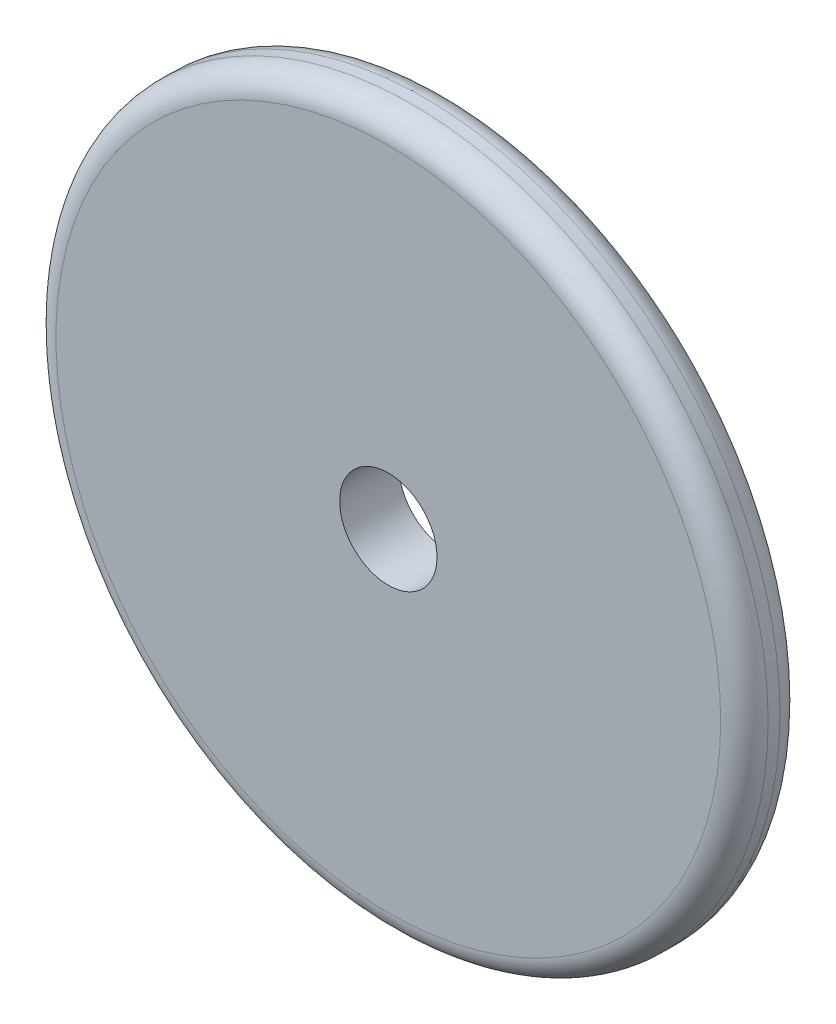
from build123d import *

# Parameters (mm, degrees)
SKIZZE1_R                       = 30
SKIZZE1_R_2                     = 4.1
AUFSATZ_LINEAR_AUSTRAGEN1_DEPTH = 2.5
VERRUNDUNG1_R                   = 2


with BuildPart() as part:
    # Skizze1 → Aufsatz-Linear austragen1 (new body, symmetric)
    with BuildSketch(Plane.XY):
        Circle(SKIZZE1_R)
        Circle(SKIZZE1_R_2, mode=Mode.SUBTRACT)
    extrude(amount=AUFSATZ_LINEAR_AUSTRAGEN1_DEPTH, both=True)

    # Verrundung1
    verrundung1_edges = [part.edges().sort_by_distance(p)[0] for p in [
        (-30, 0, -2.5),
        (-30, 0, 2.5),
    ]]
    fillet(verrundung1_edges, radius=VERRUNDUNG1_R)


solid = part.part
